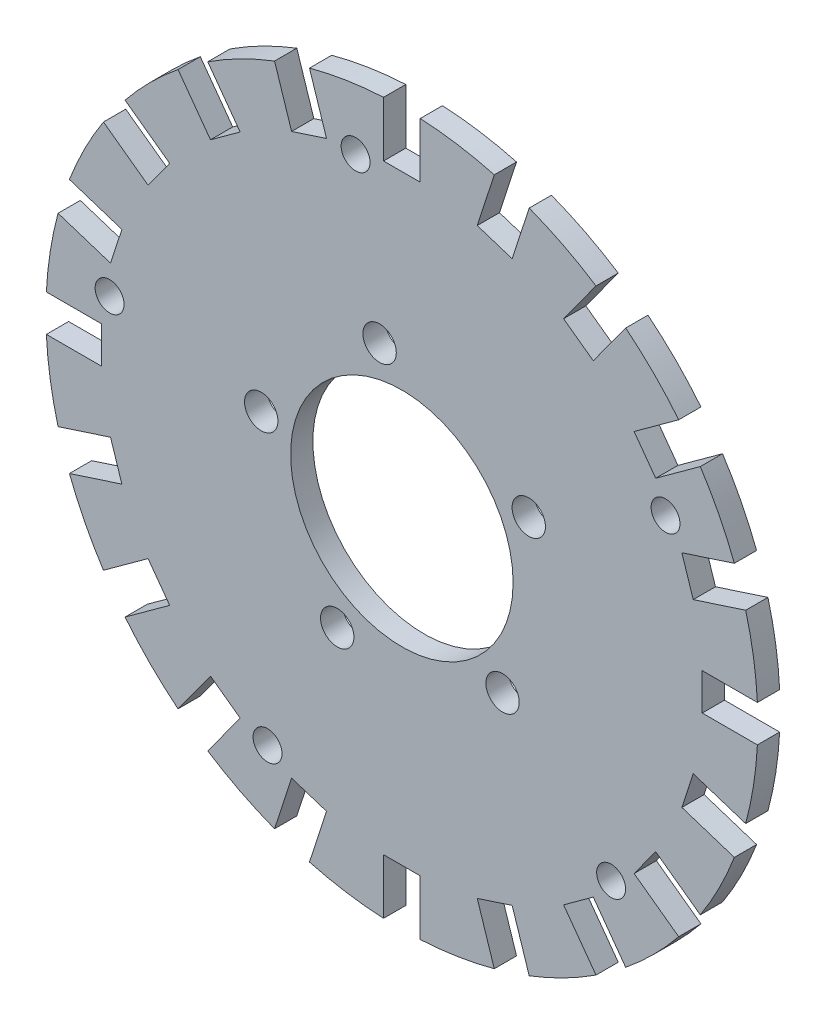
from build123d import *

# Parameters (mm, degrees)
ESQUISSE1_R                  = 160
ESQUISSE1_R_2                = 50
BOSS_EXTRU_1_DEPTH           = 5
ESQUISSE2_R                  = 7.5
ENL_V_MAT_EXTRU_1_DEPTH      = 11
ESQUISSE3_W                  = 16.5
ESQUISSE3_H                  = 25
ENL_V_MAT_EXTRU_2_DEPTH      = 11
ESQUISSE4_R                  = 6.5
ENL_V_MAT_EXTRU_3_DEPTH      = 11
R_P_TITION_CIRCULAIRE1_COUNT = 5
R_P_TITION_CIRCULAIRE2_COUNT = 20


with BuildPart() as part:
    # Esquisse1 → Boss.-Extru.1 (new body, symmetric)
    with BuildSketch(Plane.XY):
        Circle(ESQUISSE1_R)
        Circle(ESQUISSE1_R_2, mode=Mode.SUBTRACT)
    extrude(amount=BOSS_EXTRU_1_DEPTH, both=True)

    # Esquisse2 → Enlèv. mat.-Extru.1 (cut, through all)
    with BuildSketch(Plane.XY.offset(5)):
        with Locations((-10.011805763, 63.212053798)):
            Circle(ESQUISSE2_R)
    enl_v_mat_extru_1 = extrude(amount=-ENL_V_MAT_EXTRU_1_DEPTH, mode=Mode.SUBTRACT)

    # Esquisse3 → Enlèv. mat.-Extru.2 (cut, through all)
    with BuildSketch(Plane.XY.offset(5)):
        with Locations((0, 147.5)):
            Rectangle(ESQUISSE3_W, ESQUISSE3_H)
    enl_v_mat_extru_2 = extrude(amount=-ENL_V_MAT_EXTRU_2_DEPTH, mode=Mode.SUBTRACT)

    # Esquisse4 → Enlèv. mat.-Extru.3 (cut, through all)
    with BuildSketch(Plane.XY.offset(5)):
        with Locations((-20.80578385, 131.362549299)):
            Circle(ESQUISSE4_R)
    enl_v_mat_extru_3 = extrude(amount=-ENL_V_MAT_EXTRU_3_DEPTH, mode=Mode.SUBTRACT)

    # Répétition circulaire1: Enlèv. mat.-Extru.1, Enlèv. mat.-Extru.3 ×5 about axis
    r_p_tition_circulaire1_axis = Axis((0, 0, 0), (0, 0, 1))
    add([enl_v_mat_extru_1.rotate(r_p_tition_circulaire1_axis, i * 360 / R_P_TITION_CIRCULAIRE1_COUNT) for i in range(1, R_P_TITION_CIRCULAIRE1_COUNT)], mode=Mode.SUBTRACT)
    add([enl_v_mat_extru_3.rotate(r_p_tition_circulaire1_axis, i * 360 / R_P_TITION_CIRCULAIRE1_COUNT) for i in range(1, R_P_TITION_CIRCULAIRE1_COUNT)], mode=Mode.SUBTRACT)

    # Répétition circulaire2: Enlèv. mat.-Extru.2 ×20 about axis
    r_p_tition_circulaire2_axis = Axis((0, 0, 0), (0, 0, 1))
    for i in range(1, R_P_TITION_CIRCULAIRE2_COUNT):
        add(enl_v_mat_extru_2.rotate(r_p_tition_circulaire2_axis, i * 360 / R_P_TITION_CIRCULAIRE2_COUNT), mode=Mode.SUBTRACT)


solid = part.part
